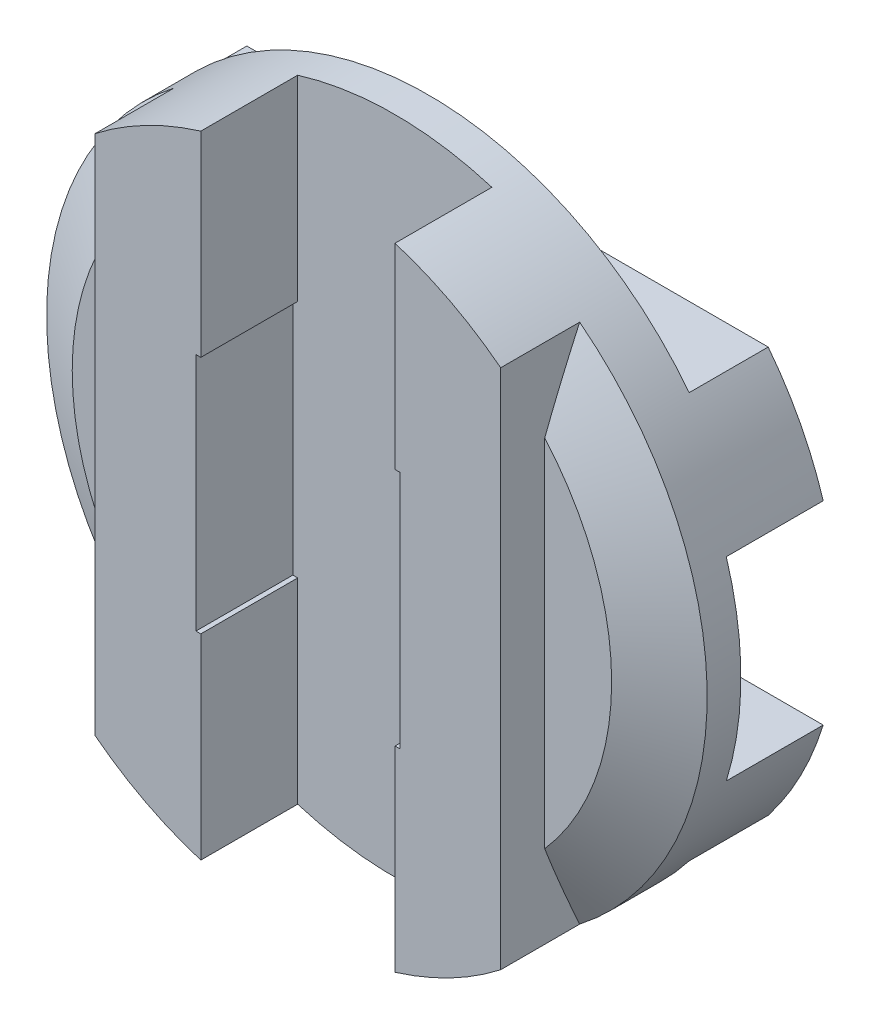
from build123d import *

# Parameters (mm, degrees)
SKETCH1_R             = 9.525
BOSS_EXTRUDE1_DEPTH   = 3.0226
SKETCH2_W             = 5.6007
SKETCH2_H             = 19.05
CUT_EXTRUDE1_DEPTH    = 2.794
SKETCH3_W             = 19.05
SKETCH3_H             = 5.6007
CUT_EXTRUDE2_DEPTH    = 2.794
SKETCH4_W             = 3.67665
SKETCH4_H             = 19.05
CUT_EXTRUDE3_DEPTH    = 1.27
SKETCH5_W             = 19.05
SKETCH5_H             = 3.67665
CUT_EXTRUDE4_DEPTH    = 1.27
CHAMFER1_SIZE         = 1.74640875
CHAMFER1_SIZE2        = 1.008289562
CHAMFER1_PART_2_SIZE  = 1.74640875
CHAMFER1_PART_2_SIZE2 = 1.008289562
CHAMFER1_PART_3_SIZE  = 1.74640875
CHAMFER1_PART_3_SIZE2 = 1.008289562
CHAMFER1_PART_4_SIZE  = 1.74640875
CHAMFER1_PART_4_SIZE2 = 1.008289562
SKETCH6_W             = 5.880735
SKETCH6_H             = 6.905625
CUT_EXTRUDE5_DEPTH    = 2.794
SKETCH7_W             = 6.905625
SKETCH7_H             = 5.880735
CUT_EXTRUDE6_DEPTH    = 2.794


with BuildPart() as part:
    # Sketch1 → Boss-Extrude1 (new body, symmetric)
    with BuildSketch(Plane.XY):
        Circle(SKETCH1_R)
    extrude(amount=BOSS_EXTRUDE1_DEPTH, both=True)

    # Sketch2 → Cut-Extrude1 (cut)
    with BuildSketch(Plane.XY.offset(3.0226)):
        Rectangle(SKETCH2_W, SKETCH2_H)
    extrude(amount=-CUT_EXTRUDE1_DEPTH, mode=Mode.SUBTRACT)

    # Sketch3 → Cut-Extrude2 (cut)
    with BuildSketch(Plane(origin=(0, 0, -3.0226), x_dir=(-1, 0, 0), z_dir=(0, 0, -1))):
        Rectangle(SKETCH3_W, SKETCH3_H)
    extrude(amount=-CUT_EXTRUDE2_DEPTH, mode=Mode.SUBTRACT)

    # Sketch4 → Cut-Extrude3 (cut)
    with BuildSketch(Plane.XY.offset(3.0226)):
        with Locations((7.686675, 0)):
            Rectangle(SKETCH4_W, SKETCH4_H)
        with Locations((-7.686675, 0)):
            Rectangle(SKETCH4_W, SKETCH4_H)
    extrude(amount=-CUT_EXTRUDE3_DEPTH, mode=Mode.SUBTRACT)

    # Sketch5 → Cut-Extrude4 (cut)
    with BuildSketch(Plane(origin=(0, 0, -3.0226), x_dir=(-1, 0, 0), z_dir=(0, 0, -1))):
        with Locations((0, 7.686675)):
            Rectangle(SKETCH5_W, SKETCH5_H)
        with Locations((0, -7.686675)):
            Rectangle(SKETCH5_W, SKETCH5_H)
    extrude(amount=-CUT_EXTRUDE4_DEPTH, mode=Mode.SUBTRACT)

    # Chamfer1
    chamfer1_edges = [part.edges().sort_by_distance(p)[0] for p in [
        (0, 9.525, -1.7526),
    ]]
    chamfer1_side = [part.faces().sort_by_distance(p)[0] for p in [
        (0, 7.346425268, -1.7526),
    ]]
    chamfer(chamfer1_edges, length=CHAMFER1_SIZE, length2=CHAMFER1_SIZE2, reference=chamfer1_side[0])

    # Chamfer1 part 2
    chamfer1_part_2_edges = [part.edges().sort_by_distance(p)[0] for p in [
        (0, -9.525, -1.7526),
    ]]
    chamfer1_part_2_side = [part.faces().sort_by_distance(p)[0] for p in [
        (0, -7.346425268, -1.7526),
    ]]
    chamfer(chamfer1_part_2_edges, length=CHAMFER1_PART_2_SIZE, length2=CHAMFER1_PART_2_SIZE2, reference=chamfer1_part_2_side[0])

    # Chamfer1 part 3
    chamfer1_part_3_edges = [part.edges().sort_by_distance(p)[0] for p in [
        (8.556610274, -4.184500642, 1.7526),
    ]]
    chamfer1_part_3_side = [part.faces().sort_by_distance(p)[0] for p in [
        (7.346425268, 0, 1.7526),
    ]]
    chamfer(chamfer1_part_3_edges, length=CHAMFER1_PART_3_SIZE, length2=CHAMFER1_PART_3_SIZE2, reference=chamfer1_part_3_side[0])

    # Chamfer1 part 4
    chamfer1_part_4_edges = [part.edges().sort_by_distance(p)[0] for p in [
        (-9.525, 0, 1.7526),
    ]]
    chamfer1_part_4_side = [part.faces().sort_by_distance(p)[0] for p in [
        (-7.346425268, 0, 1.7526),
    ]]
    chamfer(chamfer1_part_4_edges, length=CHAMFER1_PART_4_SIZE, length2=CHAMFER1_PART_4_SIZE2, reference=chamfer1_part_4_side[0])

    # Sketch6 → Cut-Extrude5 (cut)
    with BuildSketch(Plane.XY.offset(3.0226)):
        Rectangle(SKETCH6_W, SKETCH6_H)
    extrude(amount=-CUT_EXTRUDE5_DEPTH, mode=Mode.SUBTRACT)

    # Sketch7 → Cut-Extrude6 (cut)
    with BuildSketch(Plane(origin=(0, 0, -3.0226), x_dir=(-1, 0, 0), z_dir=(0, 0, -1))):
        Rectangle(SKETCH7_W, SKETCH7_H)
    extrude(amount=-CUT_EXTRUDE6_DEPTH, mode=Mode.SUBTRACT)


solid = part.part
